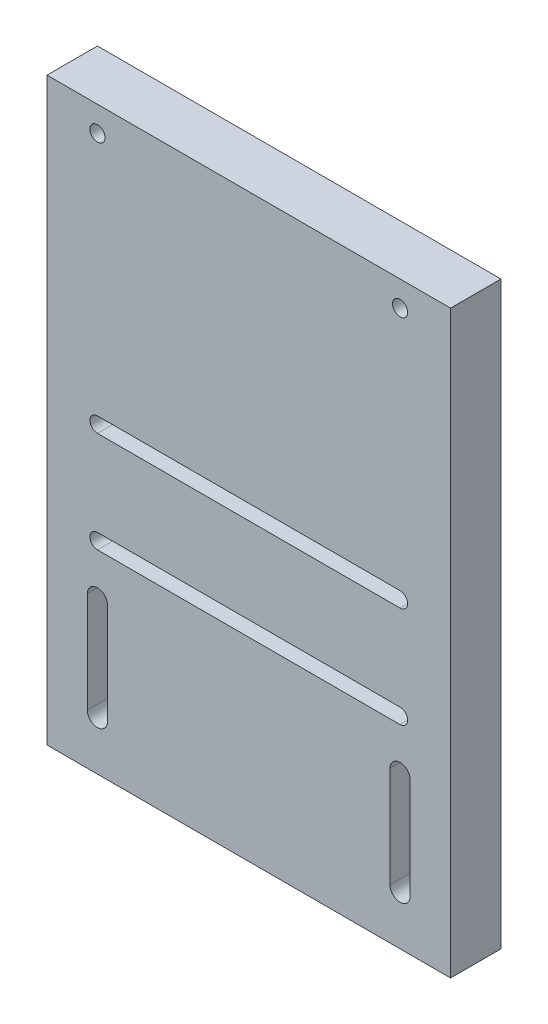
from build123d import *

# Parameters (mm, degrees)
ESQUISSE1_W        = 80
ESQUISSE1_H        = 115
ESQUISSE1_R        = 1.5
BOSS_EXTRU_1_DEPTH = 10


with BuildPart() as part:
    # Esquisse1 → Boss.-Extru.1 (new body)
    with BuildSketch(Plane.XY):
        with Locations((-17.727954042, 24.701649019)):
            Rectangle(ESQUISSE1_W, ESQUISSE1_H)
        with Locations((-47.727954042, 77.201649019)):
            Circle(ESQUISSE1_R, mode=Mode.SUBTRACT)
        with Locations((12.272045958, 77.201649019)):
            Circle(ESQUISSE1_R, mode=Mode.SUBTRACT)
        with BuildLine():
            Line((-47.727954042, 28.701649019), (12.272045958, 28.701649019))
            ThreePointArc((12.272045958, 28.701649019), (13.772045958, 27.201649019), (12.272045958, 25.701649019))
            Line((12.272045958, 25.701649019), (-47.727954042, 25.701649019))
            ThreePointArc((-47.727954042, 25.701649019), (-49.227954042, 27.201649019), (-47.727954042, 28.701649019))
        make_face(mode=Mode.SUBTRACT)
        with BuildLine():
            Line((-47.727954042, 8.701649019), (12.272045958, 8.701649019))
            ThreePointArc((12.272045958, 8.701649019), (13.772045958, 7.201649019), (12.272045958, 5.701649019))
            Line((12.272045958, 5.701649019), (-47.727954042, 5.701649019))
            ThreePointArc((-47.727954042, 5.701649019), (-49.227954042, 7.201649019), (-47.727954042, 8.701649019))
        make_face(mode=Mode.SUBTRACT)
        with BuildLine():
            Line((-49.727954042, -22.798350981), (-49.727954042, -2.798350981))
            ThreePointArc((-49.727954042, -2.798350981), (-47.727954042, -0.798350981), (-45.727954042, -2.798350981))
            Line((-45.727954042, -2.798350981), (-45.727954042, -22.798350981))
            ThreePointArc((-45.727954042, -22.798350981), (-47.727954042, -24.798350981), (-49.727954042, -22.798350981))
        make_face(mode=Mode.SUBTRACT)
        with BuildLine():
            Line((10.272045958, -2.798350981), (10.272045958, -22.798350981))
            ThreePointArc((10.272045958, -22.798350981), (12.272045958, -24.798350981), (14.272045958, -22.798350981))
            Line((14.272045958, -22.798350981), (14.272045958, -2.798350981))
            ThreePointArc((14.272045958, -2.798350981), (12.272045958, -0.798350981), (10.272045958, -2.798350981))
        make_face(mode=Mode.SUBTRACT)
    extrude(amount=BOSS_EXTRU_1_DEPTH)


solid = part.part
